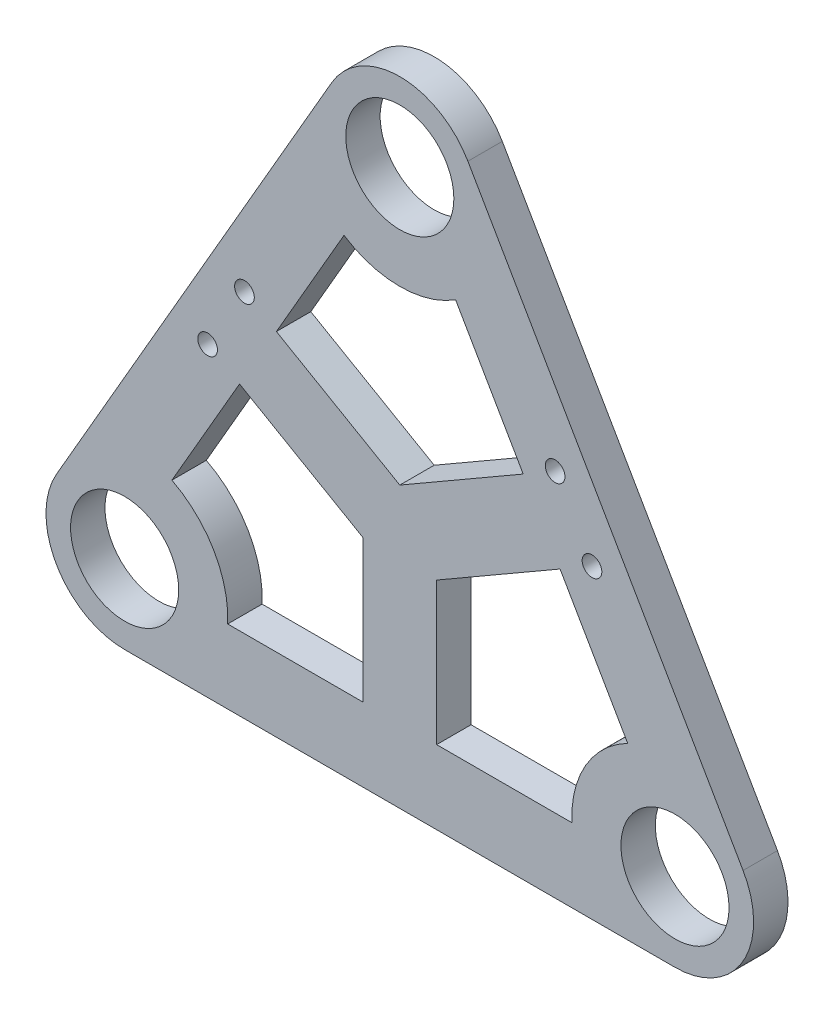
from build123d import *

# Parameters (mm, degrees)
SKETCH1_R           = 11
BOSS_EXTRUDE1_DEPTH = 7
CUT_EXTRUDE1_DEPTH  = 8
SKETCH5_R           = 2
CUT_EXTRUDE2_DEPTH  = 8


with BuildPart() as part:
    # Sketch1 → Boss-Extrude1 (new body)
    with BuildSketch(Plane.XY):
        with BuildLine():
            Line((42.143593539, 104.994845224), (-13.856406461, 8))
            ThreePointArc((-13.856406461, 8), (-13.856406461, -8), (0, -16))
            Line((0, -16), (112, -16))
            ThreePointArc((112, -16), (125.856406461, -8), (125.856406461, 8))
            Line((125.856406461, 8), (69.856406461, 104.994845224))
            ThreePointArc((69.856406461, 104.994845224), (56, 112.994845224), (42.143593539, 104.994845224))
        make_face()
        Circle(SKETCH1_R, mode=Mode.SUBTRACT)
        with Locations((112, 0)):
            Circle(SKETCH1_R, mode=Mode.SUBTRACT)
        with Locations((56, 96.994845224)):
            Circle(SKETCH1_R, mode=Mode.SUBTRACT)
    extrude(amount=BOSS_EXTRUDE1_DEPTH)

    # Sketch2 → Cut-Extrude1 (cut, through all)
    with BuildSketch(Plane.XY.offset(7)):
        with BuildLine():
            Line((9.622063078, 18.665902125), (23.383974596, 42.502232084))
            Line((23.383974596, 42.502232084), (48.5, 28.001488056))
            Line((48.5, 28.001488056), (48.5, -1))
            Line((48.5, -1), (20.976176963, -1))
            ThreePointArc((20.976176963, -1), (18.186533479, 10.5), (9.622063078, 18.665902125))
        make_face()
        with BuildLine():
            Line((63.5, -1), (91.023823037, -1))
            ThreePointArc((91.023823037, -1), (93.813466521, 10.5), (102.377936922, 18.665902125))
            Line((102.377936922, 18.665902125), (88.616025404, 42.502232084))
            Line((88.616025404, 42.502232084), (63.5, 28.001488056))
            Line((63.5, 28.001488056), (63.5, -1))
        make_face()
        with BuildLine():
            Line((30.883974596, 55.49261314), (44.645886115, 79.328943099))
            ThreePointArc((44.645886115, 79.328943099), (56, 75.994845224), (67.354113885, 79.328943099))
            Line((67.354113885, 79.328943099), (81.116025404, 55.49261314))
            Line((81.116025404, 55.49261314), (56, 40.991869112))
            Line((56, 40.991869112), (30.883974596, 55.49261314))
        make_face()
    extrude(amount=-CUT_EXTRUDE1_DEPTH, mode=Mode.SUBTRACT)

    # Sketch5 → Cut-Extrude2 (cut, through all)
    with BuildSketch(Plane.XY.offset(7)):
        with Locations((24.388784068, 59.24261314)):
            Circle(SKETCH5_R)
        with Locations((16.888784068, 46.252232084)):
            Circle(SKETCH5_R)
        with Locations((87.611215932, 59.24261314)):
            Circle(SKETCH5_R)
        with Locations((95.111215932, 46.252232084)):
            Circle(SKETCH5_R)
    extrude(amount=-CUT_EXTRUDE2_DEPTH, mode=Mode.SUBTRACT)


solid = part.part
